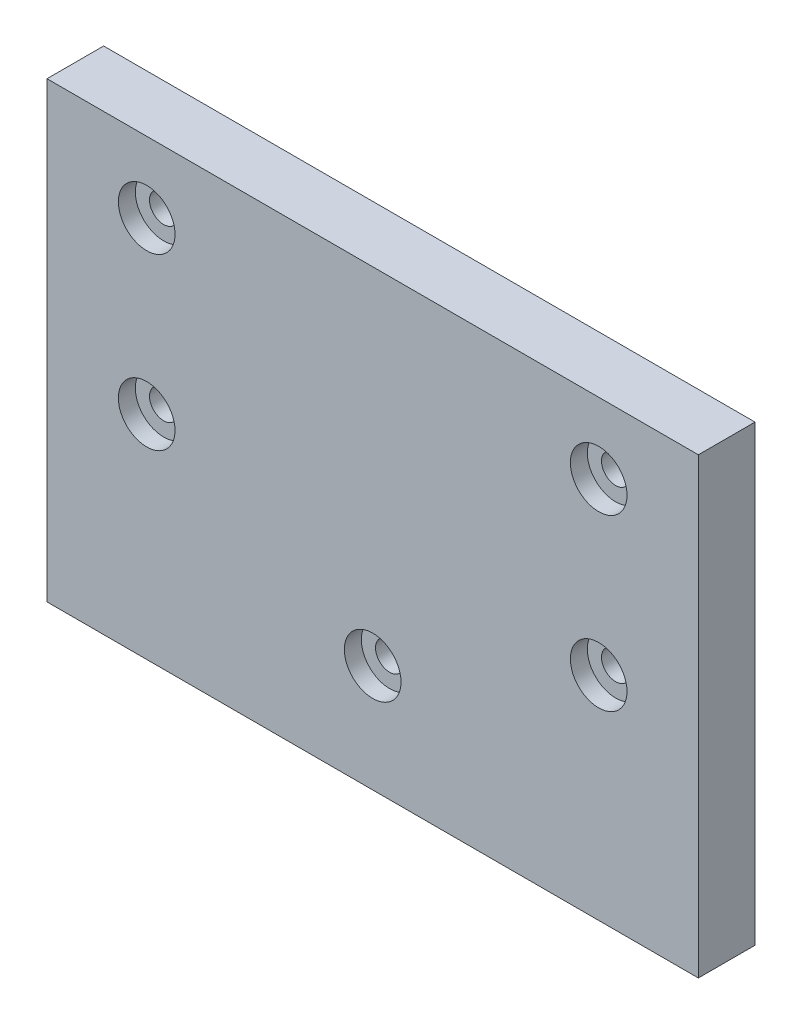
from build123d import *

# Parameters (mm, degrees)
SKETCH1_W            = 115
SKETCH1_H            = 80
BOSS_EXTRUDE1_DEPTH  = 10
SKETCH2_R            = 2.5
CUT_EXTRUDE1_DEPTH   = 10
LPATTERN1_COUNT      = 2
LPATTERN1_PITCH      = 79.8
LPATTERN1_COUNT_DIR2 = 2
LPATTERN1_PITCH_DIR2 = 30
SKETCH4_R            = 5
CUT_EXTRUDE2_DEPTH   = 3
LPATTERN2_COUNT      = 2
LPATTERN2_PITCH      = 79.8
LPATTERN2_COUNT_DIR2 = 2
LPATTERN2_PITCH_DIR2 = 30
SKETCH5_R            = 2.5
CUT_EXTRUDE3_DEPTH   = 11
SKETCH6_R            = 5
CUT_EXTRUDE4_DEPTH   = 3


with BuildPart() as part:
    # Sketch1 → Boss-Extrude1 (new body)
    with BuildSketch(Plane.XY):
        Rectangle(SKETCH1_W, SKETCH1_H)
    extrude(amount=BOSS_EXTRUDE1_DEPTH)

    # Sketch2 → Cut-Extrude1 (cut)
    with BuildSketch(Plane.XY.offset(10)):
        with Locations((-39.9, 27.5)):
            Circle(SKETCH2_R)
    cut_extrude1 = extrude(amount=-CUT_EXTRUDE1_DEPTH, mode=Mode.SUBTRACT)

    # LPattern1: Cut-Extrude1 2 × 2
    with Locations(*[(i * LPATTERN1_PITCH, -j * LPATTERN1_PITCH_DIR2, 0) for i in range(LPATTERN1_COUNT) for j in range(LPATTERN1_COUNT_DIR2) if (i, j) != (0, 0)]):
        add(cut_extrude1, mode=Mode.SUBTRACT)

    # Sketch4 → Cut-Extrude2 (cut)
    with BuildSketch(Plane.XY.offset(10)):
        with Locations((-39.9, 27.5)):
            Circle(SKETCH4_R)
    cut_extrude2 = extrude(amount=-CUT_EXTRUDE2_DEPTH, mode=Mode.SUBTRACT)

    # LPattern2: Cut-Extrude2 2 × 2
    with Locations(*[(i * LPATTERN2_PITCH, -j * LPATTERN2_PITCH_DIR2, 0) for i in range(LPATTERN2_COUNT) for j in range(LPATTERN2_COUNT_DIR2) if (i, j) != (0, 0)]):
        add(cut_extrude2, mode=Mode.SUBTRACT)

    # Sketch5 → Cut-Extrude3 (cut, through all)
    with BuildSketch(Plane.XY.offset(10)):
        with Locations((0, -21.009684694)):
            Circle(SKETCH5_R)
    extrude(amount=-CUT_EXTRUDE3_DEPTH, mode=Mode.SUBTRACT)

    # Sketch6 → Cut-Extrude4 (cut)
    with BuildSketch(Plane.XY.offset(10)):
        with Locations((0, -21.009684694)):
            Circle(SKETCH6_R)
    extrude(amount=-CUT_EXTRUDE4_DEPTH, mode=Mode.SUBTRACT)


solid = part.part
